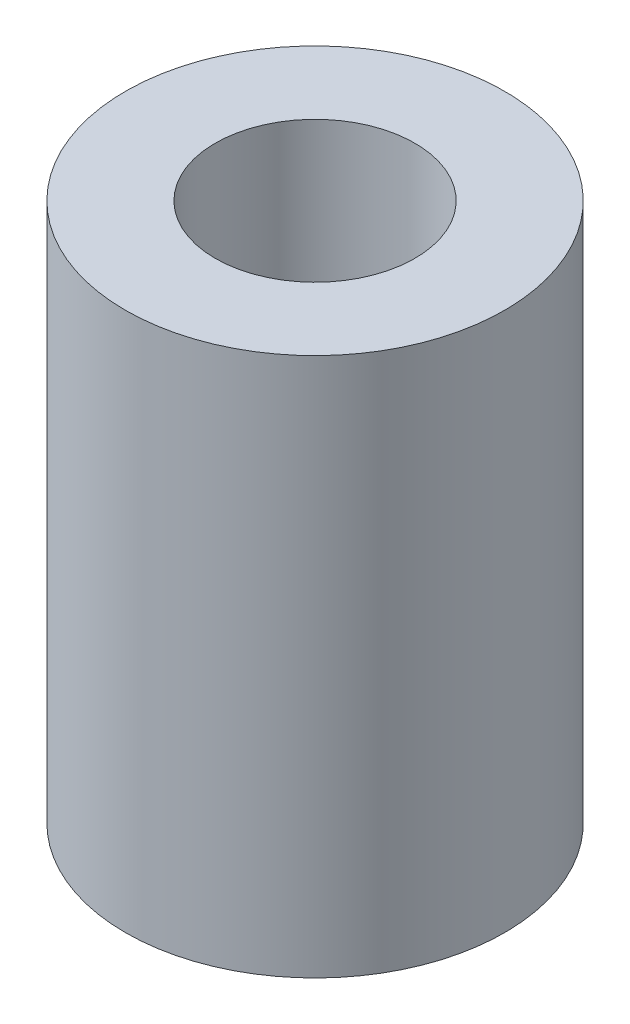
from build123d import *

# Parameters (mm, degrees)
SKETCH1_R           = 4.75
BOSS_EXTRUDE1_DEPTH = 13.5
SKETCH2_R           = 2.5
CUT_EXTRUDE1_DEPTH  = 7


with BuildPart() as part:
    # Sketch1 → Boss-Extrude1 (new body)
    with BuildSketch(Plane(origin=(0, 0, 0), x_dir=(1, 0, 0), z_dir=(0, 1, 0))):
        Circle(SKETCH1_R)
    extrude(amount=BOSS_EXTRUDE1_DEPTH)

    # Sketch2 → Cut-Extrude1 (cut)
    with BuildSketch(Plane(origin=(0, 13.5, 0), x_dir=(1, 0, 0), z_dir=(0, 1, 0))):
        Circle(SKETCH2_R)
    extrude(amount=-CUT_EXTRUDE1_DEPTH, mode=Mode.SUBTRACT)


solid = part.part
